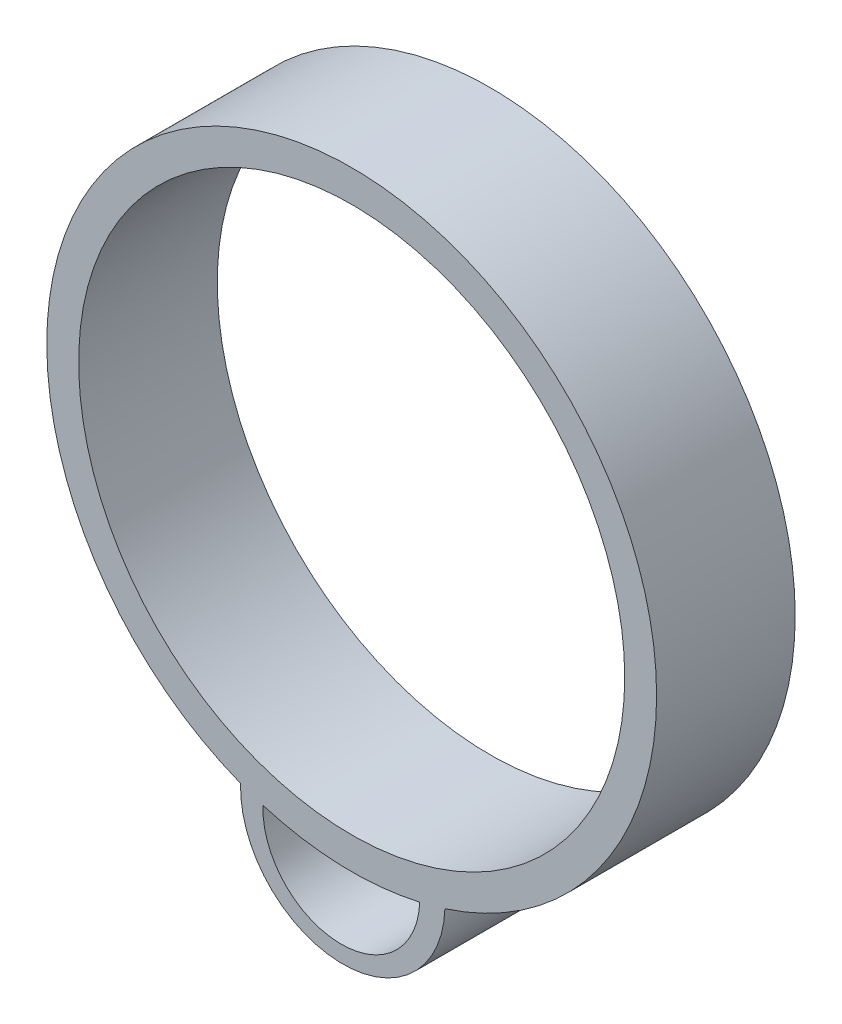
from build123d import *

# Parameters (mm, degrees)
SKETCH1_R           = 27.94
SKETCH1_R_2         = 25.019
BOSS_EXTRUDE1_DEPTH = 12.7


with BuildPart() as part:
    # Sketch1 → Boss-Extrude1 (new body)
    with BuildSketch(Plane.XY):
        with BuildLine():
            ThreePointArc((-8.131862647, -26.730439762), (-9.164248984, -26.394320233), (-10.182796999, -26.018344399))
            ThreePointArc((-10.182796999, -26.018344399), (-1.113760176, -35.671945029), (8.539840454, -26.602908206))
            ThreePointArc((8.539840454, -26.602908206), (7.392494358, -26.944287468), (6.231578661, -27.236208021))
            ThreePointArc((6.231578661, -27.236208021), (-1.203026122, -34.165044546), (-8.131862647, -26.730439762))
        make_face()
        Circle(SKETCH1_R)
        Circle(SKETCH1_R_2, mode=Mode.SUBTRACT)
    extrude(amount=BOSS_EXTRUDE1_DEPTH)


solid = part.part
